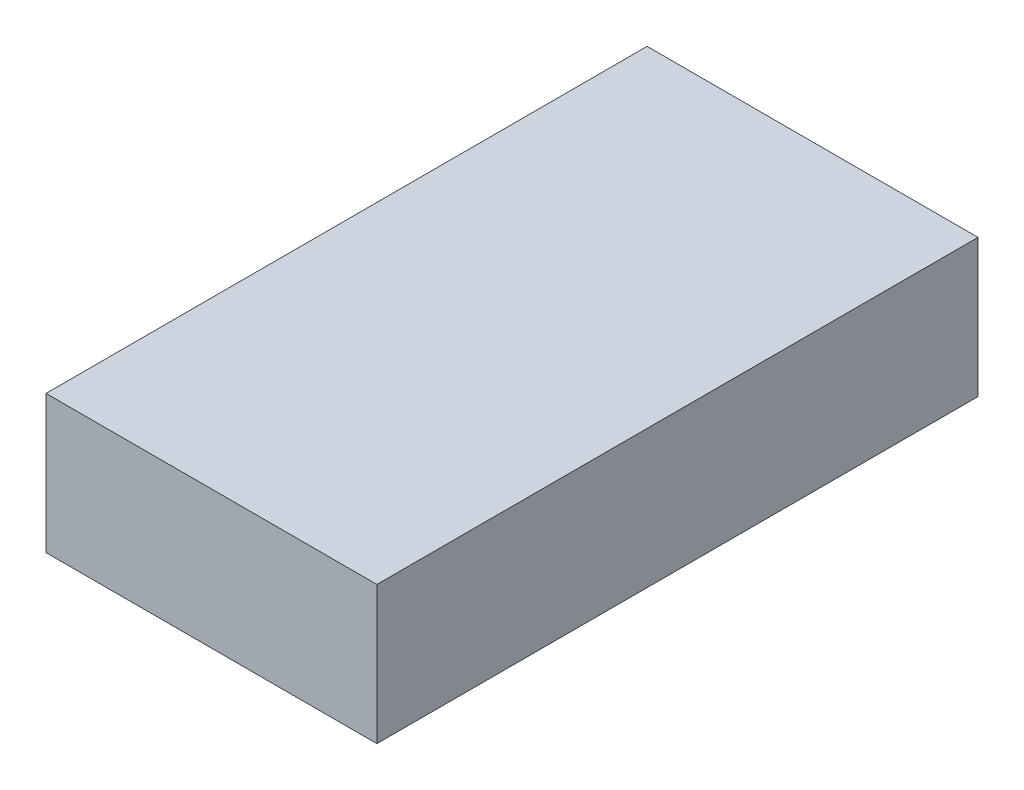
from build123d import *

# Parameters (mm, degrees)
CROQUIS1_W              = 12
CROQUIS1_H              = 5
SALIENTE_EXTRUIR1_DEPTH = 21.8


with BuildPart() as part:
    # Croquis1 → Saliente-Extruir1 (new body)
    with BuildSketch(Plane.XY):
        with Locations((-13.146002022, 2.5)):
            Rectangle(CROQUIS1_W, CROQUIS1_H)
    extrude(amount=SALIENTE_EXTRUIR1_DEPTH)


solid = part.part
